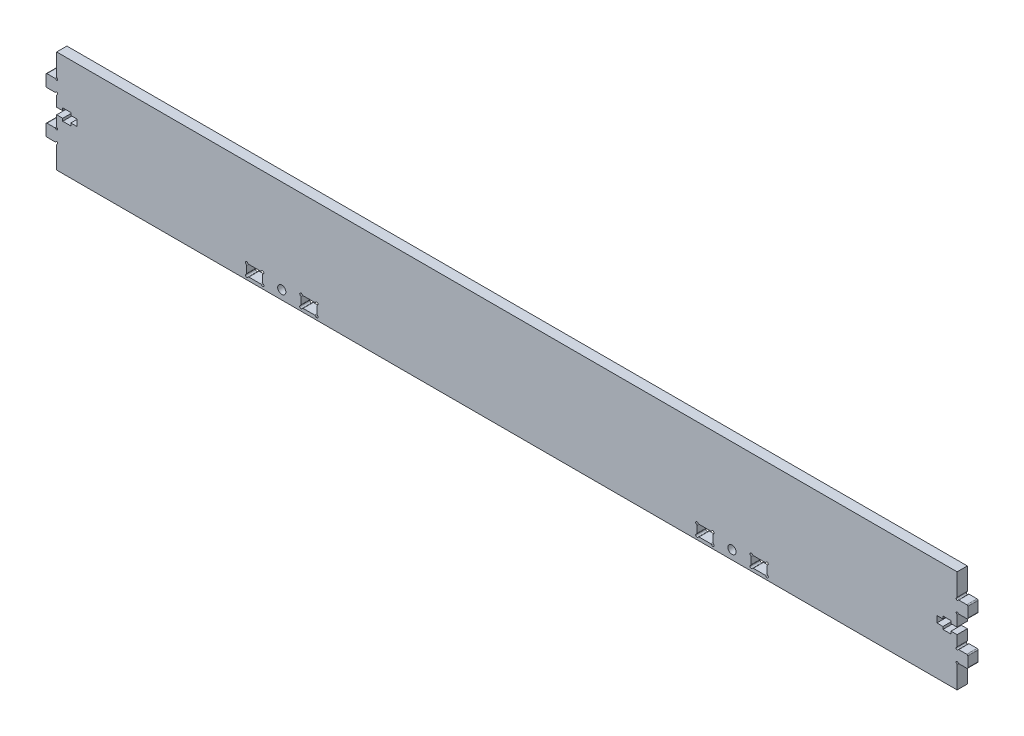
from build123d import *

# Parameters (mm, degrees)
CROQUIS1_R              = 1.6
SALIENTE_EXTRUIR1_DEPTH = 4


with BuildPart() as part:
    # Croquis1 → Saliente-Extruir1 (new body)
    with BuildSketch(Plane.XY):
        with BuildLine():
            Line((-175.998887973, 19.999997205), (176.001112027, 19.999997205))
            Line((176.001112027, 19.999997205), (176.001112027, 11.448654365))
            ThreePointArc((176.001112027, 11.448654365), (175.948097085, 11.250799991), (175.80325758, 11.105960579))
            ThreePointArc((175.80325758, 11.105960579), (175.721303049, 10.483459005), (176.343804886, 10.565411535))
            ThreePointArc((176.343804886, 10.565411535), (176.488644214, 10.710250256), (176.686498037, 10.763264881))
            Line((176.686498037, 10.763264881), (179.771113402, 10.763264881))
            ThreePointArc((179.771113402, 10.763264881), (180.050921638, 10.647364515), (180.166822004, 10.367556278))
            Line((180.166822004, 10.367556278), (180.166822004, 6.410471848))
            ThreePointArc((180.166822004, 6.410471848), (180.050921638, 6.130663611), (179.771113402, 6.014763245))
            Line((179.771113402, 6.014763245), (176.686499905, 6.014763245))
            ThreePointArc((176.686499905, 6.014763245), (176.488644215, 6.067778947), (176.343804599, 6.212620324))
            ThreePointArc((176.343804599, 6.212620324), (175.721301631, 6.294577613), (175.803256359, 5.672074308))
            ThreePointArc((175.803256359, 5.672074308), (175.948096732, 5.527234802), (176.001112027, 5.329379817))
            Line((176.001112027, 5.329379817), (176.001112027, 1.266271882))
            Line((176.001112027, 1.266271882), (173.62688257, 1.266271882))
            Line((173.62688257, 1.266271882), (173.62688257, 2.275324071))
            Line((173.62688257, 2.275324071), (170.461191588, 2.275324071))
            Line((170.461191588, 2.275324071), (170.461191588, 1.266271882))
            Line((170.461191588, 1.266271882), (168.086939971, 1.266271882))
            Line((168.086939971, 1.266271882), (168.086939971, -1.266271882))
            Line((168.086939971, -1.266271882), (170.461191588, -1.266271882))
            Line((170.461191588, -1.266271882), (170.461191588, -2.275324862))
            Line((170.461191588, -2.275324862), (173.62688257, -2.275324862))
            Line((173.62688257, -2.275324862), (173.62688257, -1.266271882))
            Line((173.62688257, -1.266271882), (176.001112027, -1.266271882))
            Line((176.001112027, -1.266271882), (176.001112027, -5.329403068))
            ThreePointArc((176.001112027, -5.329403068), (175.948097087, -5.527257438), (175.803257588, -5.67209685))
            ThreePointArc((175.803257588, -5.67209685), (175.721303071, -6.294598426), (176.343804907, -6.212645881))
            ThreePointArc((176.343804907, -6.212645881), (176.488644235, -6.067807154), (176.686498062, -6.014792528))
            Line((176.686498062, -6.014792528), (179.771113402, -6.014792528))
            ThreePointArc((179.771113402, -6.014792528), (180.050921638, -6.130692894), (180.166822004, -6.41050113))
            Line((180.166822004, -6.41050113), (180.166822004, -10.367585576))
            ThreePointArc((180.166822004, -10.367585576), (180.050921638, -10.647393813), (179.771113402, -10.763294179))
            Line((179.771113402, -10.763294179), (176.686499905, -10.763294179))
            ThreePointArc((176.686499905, -10.763294179), (176.488644296, -10.710278524), (176.343804693, -10.565437263))
            ThreePointArc((176.343804693, -10.565437263), (175.721301792, -10.483480167), (175.803256453, -11.105983388))
            ThreePointArc((175.803256453, -11.105983388), (175.94809676, -11.250822888), (176.001112027, -11.448677826))
            Line((176.001112027, -11.448677826), (176.001112027, -20.000002795))
            Line((176.001112027, -20.000002795), (-175.998887973, -20.000002795))
            Line((-175.998887973, -20.000002795), (-175.998887973, -11.448680621))
            ThreePointArc((-175.998887973, -11.448680621), (-175.945872705, -11.250825683), (-175.801032398, -11.105986184))
            ThreePointArc((-175.801032398, -11.105986184), (-175.719077737, -10.483482962), (-176.341580638, -10.565440059))
            ThreePointArc((-176.341580638, -10.565440059), (-176.486420241, -10.710281319), (-176.68427585, -10.763296974))
            Line((-176.68427585, -10.763296974), (-179.768889347, -10.763296974))
            ThreePointArc((-179.768889347, -10.763296974), (-180.048697583, -10.647396608), (-180.16459795, -10.367588371))
            Line((-180.16459795, -10.367588371), (-180.16459795, -6.410503926))
            ThreePointArc((-180.16459795, -6.410503926), (-180.048697583, -6.130695689), (-179.768889347, -6.014795323))
            Line((-179.768889347, -6.014795323), (-176.684274007, -6.014795323))
            ThreePointArc((-176.684274007, -6.014795323), (-176.48642018, -6.067809949), (-176.341580852, -6.212648677))
            ThreePointArc((-176.341580852, -6.212648677), (-175.719079017, -6.294601221), (-175.801033533, -5.672099645))
            ThreePointArc((-175.801033533, -5.672099645), (-175.945873032, -5.527260234), (-175.998887973, -5.329405863))
            Line((-175.998887973, -5.329405863), (-175.998887973, -1.266274677))
            Line((-175.998887973, -1.266274677), (-173.624658515, -1.266274677))
            Line((-173.624658515, -1.266274677), (-173.624658515, -2.275327657))
            Line((-173.624658515, -2.275327657), (-170.458967533, -2.275327657))
            Line((-170.458967533, -2.275327657), (-170.458967533, -1.266274677))
            Line((-170.458967533, -1.266274677), (-168.084715916, -1.266274677))
            Line((-168.084715916, -1.266274677), (-168.084715916, 1.266274677))
            Line((-168.084715916, 1.266274677), (-170.458967533, 1.266274677))
            Line((-170.458967533, 1.266274677), (-170.458967533, 2.275321276))
            Line((-170.458967533, 2.275321276), (-173.624658515, 2.275321276))
            Line((-173.624658515, 2.275321276), (-173.624658515, 1.266269087))
            Line((-173.624658515, 1.266269087), (-175.998887973, 1.266269087))
            Line((-175.998887973, 1.266269087), (-175.998887973, 5.329377021))
            ThreePointArc((-175.998887973, 5.329377021), (-175.945872678, 5.527232006), (-175.801032304, 5.672071513))
            ThreePointArc((-175.801032304, 5.672071513), (-175.719077577, 6.294574818), (-176.341580544, 6.212617529))
            ThreePointArc((-176.341580544, 6.212617529), (-176.48642016, 6.067776152), (-176.68427585, 6.01476045))
            Line((-176.68427585, 6.01476045), (-179.768889347, 6.01476045))
            ThreePointArc((-179.768889347, 6.01476045), (-180.048697583, 6.130660816), (-180.16459795, 6.410469053))
            Line((-180.16459795, 6.410469053), (-180.16459795, 10.367553483))
            ThreePointArc((-180.16459795, 10.367553483), (-180.048697583, 10.647361719), (-179.768889347, 10.763262086))
            Line((-179.768889347, 10.763262086), (-176.684273983, 10.763262086))
            ThreePointArc((-176.684273983, 10.763262086), (-176.486420159, 10.710247461), (-176.341580832, 10.56540874))
            ThreePointArc((-176.341580832, 10.56540874), (-175.719078995, 10.48345621), (-175.801033525, 11.105957783))
            ThreePointArc((-175.801033525, 11.105957783), (-175.94587303, 11.250797196), (-175.998887973, 11.44865157))
            Line((-175.998887973, 11.44865157), (-175.998887973, 19.999997205))
        make_face()
        with Locations((88.001112027, -16.500002795)):
            Circle(CROQUIS1_R, mode=Mode.SUBTRACT)
        with Locations((-87.998887973, -16.500002795)):
            Circle(CROQUIS1_R, mode=Mode.SUBTRACT)
        with BuildLine():
            Line((96.367130414, -14.350040138), (100.83508001, -14.350040138))
            ThreePointArc((100.83508001, -14.350040138), (101.085081969, -14.283051709), (101.268094973, -14.100036221))
            ThreePointArc((101.268094973, -14.100036221), (102.054661693, -13.996477278), (101.951110024, -14.783044955))
            ThreePointArc((101.951110024, -14.783044955), (101.768097383, -14.96605765), (101.70111011, -15.216057607))
            Line((101.70111011, -15.216057607), (101.70111011, -17.783927203))
            ThreePointArc((101.70111011, -17.783927203), (101.768097421, -18.033927226), (101.951110155, -18.216939931))
            ThreePointArc((101.951110155, -18.216939931), (102.054664397, -19.003505242), (101.268098613, -18.899954591))
            ThreePointArc((101.268098613, -18.899954591), (101.085086061, -18.716943264), (100.835087027, -18.649956524))
            Line((100.835087027, -18.649956524), (96.367137431, -18.649956524))
            ThreePointArc((96.367137431, -18.649956524), (96.117136765, -18.716944207), (95.93412396, -18.899957857))
            ThreePointArc((95.93412396, -18.899957857), (95.147558474, -19.003513955), (95.251108451, -18.216947664))
            ThreePointArc((95.251108451, -18.216947664), (95.434119704, -18.033935119), (95.501106414, -17.783936138))
            Line((95.501106414, -17.783936138), (95.501106414, -15.216068542))
            ThreePointArc((95.501106414, -15.216068542), (95.434119187, -14.966068665), (95.25110666, -14.783055982))
            ThreePointArc((95.25110666, -14.783055982), (95.147552946, -13.996490602), (95.93411866, -14.10004178))
            ThreePointArc((95.93411866, -14.10004178), (96.117131235, -14.283053314), (96.367130414, -14.350040138))
        make_face(mode=Mode.SUBTRACT)
        with BuildLine():
            Line((75.167130414, -14.350040138), (79.63508001, -14.350040138))
            ThreePointArc((79.63508001, -14.350040138), (79.885080422, -14.283052602), (80.068093188, -14.100039313))
            ThreePointArc((80.068093188, -14.100039313), (80.854658123, -13.996483462), (80.751109545, -14.783049354))
            ThreePointArc((80.751109545, -14.783049354), (80.568099104, -14.96606181), (80.501112724, -15.216060221))
            Line((80.501112724, -15.216060221), (80.501112724, -17.783929817))
            ThreePointArc((80.501112724, -17.783929817), (80.568100251, -18.033930214), (80.751113519, -18.216942978))
            ThreePointArc((80.751113519, -18.216942978), (80.85466864, -19.003508592), (80.068102477, -18.899957638))
            ThreePointArc((80.068102477, -18.899957638), (79.885089891, -18.716946003), (79.635090641, -18.649959138))
            Line((79.635090641, -18.649959138), (75.167141045, -18.649959138))
            ThreePointArc((75.167141045, -18.649959138), (74.917140379, -18.716946821), (74.734127574, -18.89996047))
            ThreePointArc((74.734127574, -18.89996047), (73.947562088, -19.003516569), (74.051112065, -18.216950277))
            ThreePointArc((74.051112065, -18.216950277), (74.234123318, -18.033937733), (74.301110027, -17.783938752))
            Line((74.301110027, -17.783938752), (74.301110027, -15.216071156))
            ThreePointArc((74.301110027, -15.216071156), (74.234122345, -14.96607049), (74.051108695, -14.783057685))
            ThreePointArc((74.051108695, -14.783057685), (73.947552596, -13.996492199), (74.734118888, -14.100042176))
            ThreePointArc((74.734118888, -14.100042176), (74.917131432, -14.283053428), (75.167130414, -14.350040138))
        make_face(mode=Mode.SUBTRACT)
        with BuildLine():
            Line((-101.698889973, -17.783938752), (-101.698889973, -15.216071156))
            ThreePointArc((-101.698889973, -15.216071156), (-101.765877655, -14.96607049), (-101.948891305, -14.783057685))
            ThreePointArc((-101.948891305, -14.783057685), (-102.052447404, -13.996492199), (-101.265881112, -14.100042176))
            ThreePointArc((-101.265881112, -14.100042176), (-101.082868568, -14.283053428), (-100.832869586, -14.350040138))
            Line((-100.832869586, -14.350040138), (-96.36491999, -14.350040138))
            ThreePointArc((-96.36491999, -14.350040138), (-96.114919578, -14.283052602), (-95.931906812, -14.100039313))
            ThreePointArc((-95.931906812, -14.100039313), (-95.145341877, -13.996483462), (-95.248890455, -14.783049354))
            ThreePointArc((-95.248890455, -14.783049354), (-95.431900896, -14.96606181), (-95.498887276, -15.216060221))
            Line((-95.498887276, -15.216060221), (-95.498887276, -17.783929817))
            ThreePointArc((-95.498887276, -17.783929817), (-95.431899749, -18.033930214), (-95.248886481, -18.216942978))
            ThreePointArc((-95.248886481, -18.216942978), (-95.14533136, -19.003508592), (-95.931897523, -18.899957638))
            ThreePointArc((-95.931897523, -18.899957638), (-96.114910109, -18.716946003), (-96.364909359, -18.649959138))
            Line((-96.364909359, -18.649959138), (-100.832858955, -18.649959138))
            ThreePointArc((-100.832858955, -18.649959138), (-101.082859621, -18.716946821), (-101.265872426, -18.89996047))
            ThreePointArc((-101.265872426, -18.89996047), (-102.052437912, -19.003516569), (-101.948887935, -18.216950277))
            ThreePointArc((-101.948887935, -18.216950277), (-101.765876682, -18.033937733), (-101.698889973, -17.783938752))
        make_face(mode=Mode.SUBTRACT)
        with BuildLine():
            Line((-74.29888989, -15.216057607), (-74.29888989, -17.783927203))
            ThreePointArc((-74.29888989, -17.783927203), (-74.231902579, -18.033927226), (-74.048889845, -18.216939931))
            ThreePointArc((-74.048889845, -18.216939931), (-73.945335603, -19.003505242), (-74.731901387, -18.899954591))
            ThreePointArc((-74.731901387, -18.899954591), (-74.914913939, -18.716943264), (-75.164912973, -18.649956524))
            Line((-75.164912973, -18.649956524), (-79.632862569, -18.649956524))
            ThreePointArc((-79.632862569, -18.649956524), (-79.882863235, -18.716944207), (-80.06587604, -18.899957857))
            ThreePointArc((-80.06587604, -18.899957857), (-80.852441526, -19.003513955), (-80.748891549, -18.216947664))
            ThreePointArc((-80.748891549, -18.216947664), (-80.565880296, -18.033935119), (-80.498893586, -17.783936138))
            Line((-80.498893586, -17.783936138), (-80.498893586, -15.216068542))
            ThreePointArc((-80.498893586, -15.216068542), (-80.565880813, -14.966068665), (-80.74889334, -14.783055982))
            ThreePointArc((-80.74889334, -14.783055982), (-80.852447054, -13.996490602), (-80.06588134, -14.10004178))
            ThreePointArc((-80.06588134, -14.10004178), (-79.882868765, -14.283053314), (-79.632869586, -14.350040138))
            Line((-79.632869586, -14.350040138), (-75.16491999, -14.350040138))
            ThreePointArc((-75.16491999, -14.350040138), (-74.914918031, -14.283051709), (-74.731905027, -14.100036221))
            ThreePointArc((-74.731905027, -14.100036221), (-73.945338307, -13.996477278), (-74.048889976, -14.783044955))
            ThreePointArc((-74.048889976, -14.783044955), (-74.231902617, -14.96605765), (-74.29888989, -15.216057607))
        make_face(mode=Mode.SUBTRACT)
    extrude(amount=SALIENTE_EXTRUIR1_DEPTH)


solid = part.part
